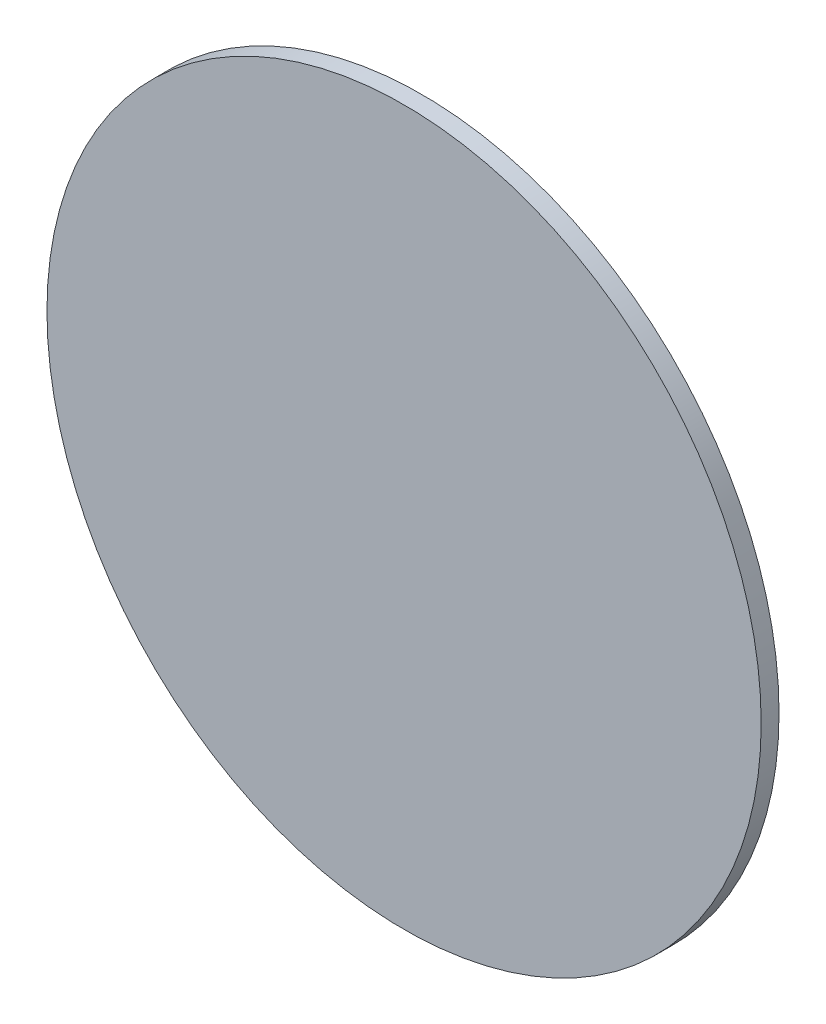
from build123d import *

# Parameters (mm, degrees)
SKETCH_1_R      = 10
EXTRUDE_1_DEPTH = 0.5


with BuildPart() as part:
    # 草图1 → 凸台-拉伸1 (new body)
    with BuildSketch(Plane.XY):
        Circle(SKETCH_1_R)
    extrude(amount=EXTRUDE_1_DEPTH)


solid = part.part
